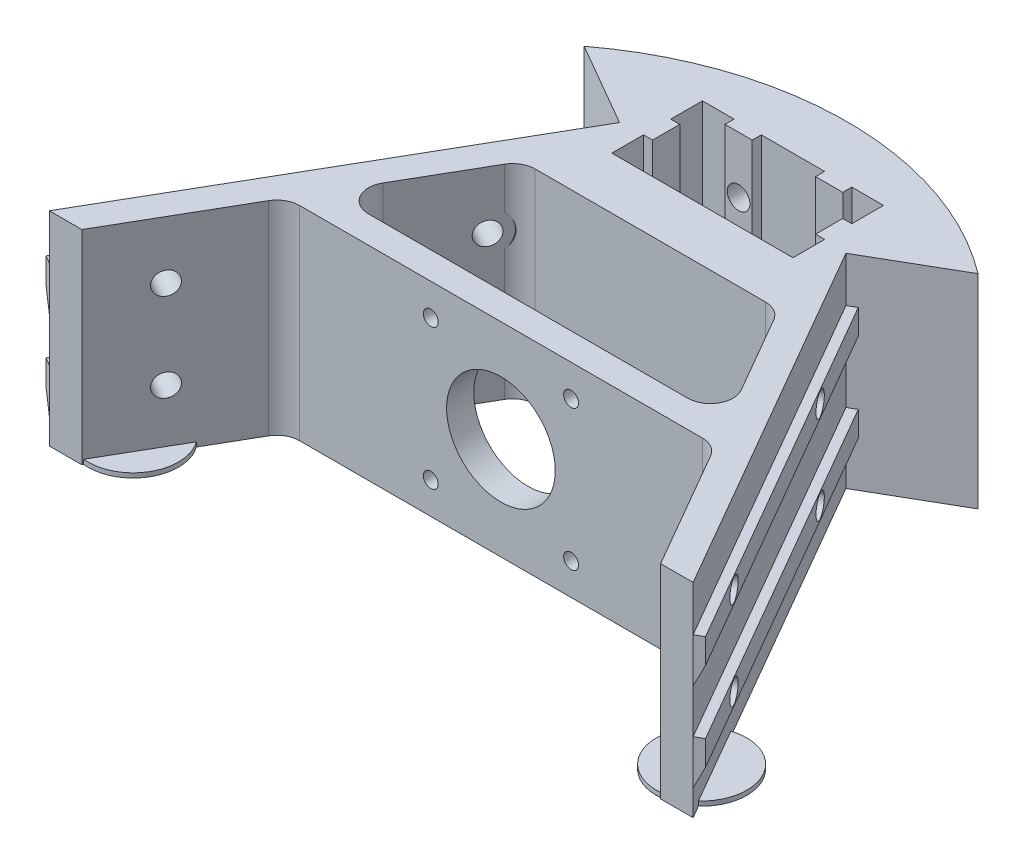
from build123d import *

# Parameters (mm, degrees)
BOSS_EXTRUDE1_DEPTH     = 45
CUT_EXTRUDE1_REACH      = 115.721
SKETCH2_R               = 12
SKETCH2_R_2             = 1.65
SKETCH3_W               = 92.200496998
SKETCH3_H               = 5.5
BOSS_EXTRUDE2_DEPTH     = 2
CUT_EXTRUDE2_REACH      = 137.868
SKETCH4_R               = 2.5
CUT_EXTRUDE6_REACH      = 130.334
SKETCH7_R               = 4.5
CUT_EXTRUDE3_REACH      = 127.051
CUT_EXTRUDE3_END_RADIUS = 72
SKETCH5_R               = 2.5
CUT_EXTRUDE5_START      = -14
SKETCH6_R               = 4.25
CUT_EXTRUDE5_DEPTH      = 1.7
SKETCH8_R               = 10
BOSS_EXTRUDE3_DEPTH     = 1
BOSS_EXTRUDE4_DEPTH     = 0.7
LPATTERN1_COUNT         = 46
LPATTERN1_PITCH         = 2
BOSS_EXTRUDE5_DEPTH     = 0.7
LPATTERN2_COUNT         = 46
LPATTERN2_PITCH         = 2


with BuildPart() as part:
    # Sketch1 → Boss-Extrude1 (new body)
    with BuildSketch(Plane(origin=(0, 0, 0), x_dir=(1, 0, 0), z_dir=(0, 1, 0))):
        with BuildLine():
            Line((67.073634163, -66.174942219), (25, 6.698729811))
            Line((25, 6.698729811), (43.49555567, 17.377143855))
            ThreePointArc((43.49555567, 17.377143855), (0, 32), (-43.49555567, 17.377143855))
            Line((-43.49555567, 17.377143855), (-25, 6.698729811))
            Line((-25, 6.698729811), (-67.073634163, -66.174942219))
            Line((-67.073634163, -66.174942219), (-71.100248499, -73.149242831))
            Line((-71.100248499, -73.149242831), (-63.915003714, -73.149242831))
            Line((-63.915003714, -73.149242831), (-48.817731326, -47))
            ThreePointArc((-48.817731326, -47), (-46.987604307, -45.169872981), (-44.487604307, -44.5))
            Line((-44.487604307, -44.5), (44.487604307, -44.5))
            ThreePointArc((44.487604307, -44.5), (46.987604307, -45.169872981), (48.817731326, -47))
            Line((48.817731326, -47), (63.915003714, -73.149242831))
            Line((63.915003714, -73.149242831), (71.100248499, -73.149242831))
            Line((71.100248499, -73.149242831), (67.073634163, -66.174942219))
        make_face()
        Polygon((-20, 20), (-13, 20), (-13, 18), (-7, 18), (-7, 20), (7, 20), (7, 18), (13, 18), (13, 20), (20, 20), (20, 13), (18, 13), (18, 7), (20, 7), (20, 0), (-20, 0), (-20, 7), (-18, 7), (-18, 13), (-20, 13), align=None, mode=Mode.SUBTRACT)
        with BuildLine():
            Line((-25.435045424, -11.5), (25.435045424, -11.5))
            ThreePointArc((25.435045424, -11.5), (27.935045424, -12.169872981), (29.765172443, -14))
            Line((29.765172443, -14), (39.580127019, -31))
            ThreePointArc((39.580127019, -31), (39.580127019, -36), (35.25, -38.5))
            Line((35.25, -38.5), (-35.25, -38.5))
            ThreePointArc((-35.25, -38.5), (-39.580127019, -36), (-39.580127019, -31))
            Line((-39.580127019, -31), (-29.765172443, -14))
            ThreePointArc((-29.765172443, -14), (-27.935045424, -12.169872981), (-25.435045424, -11.5))
        make_face(mode=Mode.SUBTRACT)
    extrude(amount=BOSS_EXTRUDE1_DEPTH)

    # Sketch2 → Cut-Extrude1 (cut, up to next)
    with BuildSketch(Plane.XY.offset(44.5), mode=Mode.PRIVATE) as cut_extrude1_sk1:
        with Locations((0, 22.5)):
            Circle(SKETCH2_R)
    cut_extrude1_tool1 = extrude(cut_extrude1_sk1.sketch, amount=-CUT_EXTRUDE1_REACH, mode=Mode.PRIVATE) & part.part
    # Sketch2 → Cut-Extrude1 (cut, up to next)
    with BuildSketch(Plane.XY.offset(44.5), mode=Mode.PRIVATE) as cut_extrude1_sk2:
        with Locations((-15.5, 38)):
            Circle(SKETCH2_R_2)
    cut_extrude1_tool2 = extrude(cut_extrude1_sk2.sketch, amount=-CUT_EXTRUDE1_REACH, mode=Mode.PRIVATE) & part.part
    # Sketch2 → Cut-Extrude1 (cut, up to next)
    with BuildSketch(Plane.XY.offset(44.5), mode=Mode.PRIVATE) as cut_extrude1_sk3:
        with Locations((15.5, 38)):
            Circle(SKETCH2_R_2)
    cut_extrude1_tool3 = extrude(cut_extrude1_sk3.sketch, amount=-CUT_EXTRUDE1_REACH, mode=Mode.PRIVATE) & part.part
    # Sketch2 → Cut-Extrude1 (cut, up to next)
    with BuildSketch(Plane.XY.offset(44.5), mode=Mode.PRIVATE) as cut_extrude1_sk4:
        with Locations((15.5, 7)):
            Circle(SKETCH2_R_2)
    cut_extrude1_tool4 = extrude(cut_extrude1_sk4.sketch, amount=-CUT_EXTRUDE1_REACH, mode=Mode.PRIVATE) & part.part
    # Sketch2 → Cut-Extrude1 (cut, up to next)
    with BuildSketch(Plane.XY.offset(44.5), mode=Mode.PRIVATE) as cut_extrude1_sk5:
        with Locations((-15.5, 7)):
            Circle(SKETCH2_R_2)
    cut_extrude1_tool5 = extrude(cut_extrude1_sk5.sketch, amount=-CUT_EXTRUDE1_REACH, mode=Mode.PRIVATE) & part.part
    add(cut_extrude1_tool1.solids().sort_by_distance((0, 22.5, 44.5))[0], mode=Mode.SUBTRACT)
    add(cut_extrude1_tool2.solids().sort_by_distance((-15.5, 38, 44.5))[0], mode=Mode.SUBTRACT)
    add(cut_extrude1_tool3.solids().sort_by_distance((15.5, 38, 44.5))[0], mode=Mode.SUBTRACT)
    add(cut_extrude1_tool4.solids().sort_by_distance((15.5, 7, 44.5))[0], mode=Mode.SUBTRACT)
    add(cut_extrude1_tool5.solids().sort_by_distance((-15.5, 7, 44.5))[0], mode=Mode.SUBTRACT)

    # Sketch3 → Boss-Extrude2 (add)
    with BuildSketch(Plane(origin=(21.650635095, 0, -12.5), x_dir=(-0.49999999999999517, 0, -0.8660254037844414), z_dir=(0.8660254037844414, 0, -0.49999999999999517))):
        with Locations((-52.79897831, 32.25)):
            Rectangle(SKETCH3_W, SKETCH3_H)
        with Locations((-52.79897831, 12.75)):
            Rectangle(SKETCH3_W, SKETCH3_H)
    boss_extrude2 = extrude(amount=BOSS_EXTRUDE2_DEPTH)

    # Sketch4 → Cut-Extrude2 (cut, up to next)
    with BuildSketch(Plane(origin=(23.382685902, 0, -13.5), x_dir=(-0.4999999999999952, 0, -0.8660254037844415), z_dir=(0.8660254037844415, 0, -0.4999999999999953)), mode=Mode.PRIVATE) as cut_extrude2_sk1:
        with Locations((-29.698729811, 32.25)):
            Circle(SKETCH4_R)
    cut_extrude2_tool1 = extrude(cut_extrude2_sk1.sketch, amount=-CUT_EXTRUDE2_REACH, mode=Mode.PRIVATE) & part.part
    # Sketch4 → Cut-Extrude2 (cut, up to next)
    with BuildSketch(Plane(origin=(23.382685902, 0, -13.5), x_dir=(-0.4999999999999952, 0, -0.8660254037844415), z_dir=(0.8660254037844415, 0, -0.4999999999999953)), mode=Mode.PRIVATE) as cut_extrude2_sk2:
        with Locations((-29.698729811, 12.75)):
            Circle(SKETCH4_R)
    cut_extrude2_tool2 = extrude(cut_extrude2_sk2.sketch, amount=-CUT_EXTRUDE2_REACH, mode=Mode.PRIVATE) & part.part
    # Sketch4 → Cut-Extrude2 (cut, up to next)
    with BuildSketch(Plane(origin=(23.382685902, 0, -13.5), x_dir=(-0.4999999999999952, 0, -0.8660254037844415), z_dir=(0.8660254037844415, 0, -0.4999999999999953)), mode=Mode.PRIVATE) as cut_extrude2_sk3:
        with Locations((-81.698729811, 12.75)):
            Circle(SKETCH4_R)
    cut_extrude2_tool3 = extrude(cut_extrude2_sk3.sketch, amount=-CUT_EXTRUDE2_REACH, mode=Mode.PRIVATE) & part.part
    # Sketch4 → Cut-Extrude2 (cut, up to next)
    with BuildSketch(Plane(origin=(23.382685902, 0, -13.5), x_dir=(-0.4999999999999952, 0, -0.8660254037844415), z_dir=(0.8660254037844415, 0, -0.4999999999999953)), mode=Mode.PRIVATE) as cut_extrude2_sk4:
        with Locations((-81.698729811, 32.25)):
            Circle(SKETCH4_R)
    cut_extrude2_tool4 = extrude(cut_extrude2_sk4.sketch, amount=-CUT_EXTRUDE2_REACH, mode=Mode.PRIVATE) & part.part
    cut_extrude2_1 = cut_extrude2_tool1.solids().sort_by_distance((38.232051, 32.25, 12.219854))[0]
    add(cut_extrude2_1, mode=Mode.SUBTRACT)
    cut_extrude2_2 = cut_extrude2_tool2.solids().sort_by_distance((38.232051, 12.75, 12.219854))[0]
    add(cut_extrude2_2, mode=Mode.SUBTRACT)
    cut_extrude2_3 = cut_extrude2_tool3.solids().sort_by_distance((64.232051, 12.75, 57.253175))[0]
    add(cut_extrude2_3, mode=Mode.SUBTRACT)
    cut_extrude2_4 = cut_extrude2_tool4.solids().sort_by_distance((64.232051, 32.25, 57.253175))[0]
    add(cut_extrude2_4, mode=Mode.SUBTRACT)
    cut_extrude2 = cut_extrude2_1 + cut_extrude2_2 + cut_extrude2_3 + cut_extrude2_4  # Cut-Extrude2 as one shape, for the pattern or mirror that repeats it

    # Sketch7 → Cut-Extrude6 (cut, up to next)
    with BuildSketch(Plane(origin=(16.261701506, 0, -9.388697742), x_dir=(0.49999999999999534, 0, 0.8660254037844414), z_dir=(-0.8660254037844415, 0, 0.4999999999999954)), mode=Mode.PRIVATE) as cut_extrude6_sk1:
        with Locations((29.698729811, 32.25)):
            Circle(SKETCH7_R)
    cut_extrude6_tool1 = extrude(cut_extrude6_sk1.sketch, amount=CUT_EXTRUDE6_REACH, mode=Mode.PRIVATE) & part.part
    # Sketch7 → Cut-Extrude6 (cut, up to next)
    with BuildSketch(Plane(origin=(16.261701506, 0, -9.388697742), x_dir=(0.49999999999999534, 0, 0.8660254037844414), z_dir=(-0.8660254037844415, 0, 0.4999999999999954)), mode=Mode.PRIVATE) as cut_extrude6_sk2:
        with Locations((29.698729811, 12.75)):
            Circle(SKETCH7_R)
    cut_extrude6_tool2 = extrude(cut_extrude6_sk2.sketch, amount=CUT_EXTRUDE6_REACH, mode=Mode.PRIVATE) & part.part
    cut_extrude6_1 = cut_extrude6_tool1.solids().sort_by_distance((31.111066, 32.25, 16.331157))[0]
    add(cut_extrude6_1, mode=Mode.SUBTRACT)
    cut_extrude6_2 = cut_extrude6_tool2.solids().sort_by_distance((31.111066, 12.75, 16.331157))[0]
    add(cut_extrude6_2, mode=Mode.SUBTRACT)
    cut_extrude6 = cut_extrude6_1 + cut_extrude6_2  # Cut-Extrude6 as one shape, for the pattern or mirror that repeats it

    # Cut-Extrude3: up to this cylinder (the profile starts inside it)
    cut_extrude3_end = Plane(origin=(0, 22.5, 40), z_dir=(0, -1, 0)) * Cylinder(CUT_EXTRUDE3_END_RADIUS, 419.102, mode=Mode.PRIVATE)
    # Sketch5 → Cut-Extrude3 (cut, up to the surface)
    with BuildSketch(Plane.XY.offset(-18), mode=Mode.PRIVATE) as cut_extrude3_sk1:
        with Locations((10, 32.5)):
            Circle(SKETCH5_R)
    cut_extrude3_tool1 = extrude(cut_extrude3_sk1.sketch, amount=-CUT_EXTRUDE3_REACH, mode=Mode.PRIVATE) & cut_extrude3_end
    # Sketch5 → Cut-Extrude3 (cut, up to the surface)
    with BuildSketch(Plane.XY.offset(-18), mode=Mode.PRIVATE) as cut_extrude3_sk2:
        with Locations((10, 12.5)):
            Circle(SKETCH5_R)
    cut_extrude3_tool2 = extrude(cut_extrude3_sk2.sketch, amount=-CUT_EXTRUDE3_REACH, mode=Mode.PRIVATE) & cut_extrude3_end
    cut_extrude3 = cut_extrude3_tool1.solids().sort_by_distance((10, 32.5, -18))[0] + cut_extrude3_tool2.solids().sort_by_distance((10, 12.5, -18))[0]
    add(cut_extrude3, mode=Mode.SUBTRACT)

    # Sketch6 → Cut-Extrude5 (cut)
    with BuildSketch(Plane.XY.offset(-18).offset(CUT_EXTRUDE5_START)):
        with Locations(Location((10, 32.5, 0), (0, 0, 180))):
            Circle(SKETCH6_R)
        with Locations(Location((10, 12.5, 0), (0, 0, 180))):
            Circle(SKETCH6_R)
    cut_extrude5 = extrude(amount=CUT_EXTRUDE5_DEPTH, mode=Mode.SUBTRACT)

    # Mirror1: Boss-Extrude2, Cut-Extrude2, Cut-Extrude6, Cut-Extrude3, Cut-Extrude5 across plane
    add(boss_extrude2.mirror(Plane(origin=(0, 0, 0), x_dir=(0, 0, 1), z_dir=(1, 0, 0))))
    add(cut_extrude2.mirror(Plane(origin=(0, 0, 0), x_dir=(0, 0, 1), z_dir=(1, 0, 0))), mode=Mode.SUBTRACT)
    add(cut_extrude6.mirror(Plane(origin=(0, 0, 0), x_dir=(0, 0, 1), z_dir=(1, 0, 0))), mode=Mode.SUBTRACT)
    add(cut_extrude3.mirror(Plane(origin=(0, 0, 0), x_dir=(0, 0, 1), z_dir=(1, 0, 0))), mode=Mode.SUBTRACT)
    add(cut_extrude5.mirror(Plane(origin=(0, 0, 0), x_dir=(0, 0, 1), z_dir=(1, 0, 0))), mode=Mode.SUBTRACT)

    # Sketch8 → Boss-Extrude3 (add)
    with BuildSketch(Plane(origin=(0, 0, 0), x_dir=(1, 0, 0), z_dir=(0, 1, 0))):
        with Locations((62.771807108, -62.946563711)):
            Circle(SKETCH8_R)
        with Locations((-62.771807108, -62.946563711)):
            Circle(SKETCH8_R)
    extrude(amount=BOSS_EXTRUDE3_DEPTH)

    # Sketch10 → Boss-Extrude4 (add)
    with BuildSketch(Plane(origin=(49.449613404, 0, 85.649242831), x_dir=(0.8660254037844415, 0, -0.4999999999999951), z_dir=(0.49999999999999517, 0, 0.8660254037844416))):
        Polygon((25, 29.5), (27, 29.5), (25, 25.210986159), align=None)
        Polygon((25, 10), (27, 10), (25, 5.710986159), align=None)
    boss_extrude4 = extrude(amount=-BOSS_EXTRUDE4_DEPTH)

    # LPattern1: Boss-Extrude4 ×46
    with Locations(*[Vector(-0.49999999999999356, 0, -0.8660254037844424) * (i * LPATTERN1_PITCH) for i in range(1, LPATTERN1_COUNT)]):
        add(boss_extrude4)

    # Sketch11 → Boss-Extrude5 (add)
    with BuildSketch(Plane(origin=(-49.449613404, 0, 85.649242831), x_dir=(0.8660254037844414, 0, 0.49999999999999534), z_dir=(-0.4999999999999954, 0, 0.8660254037844415))):
        Polygon((-25, 29.5), (-27, 29.5), (-25, 25.210986159), align=None)
        Polygon((-25, 10), (-27, 10), (-25, 5.710986159), align=None)
    boss_extrude5 = extrude(amount=-BOSS_EXTRUDE5_DEPTH)

    # LPattern2: Boss-Extrude5 ×46
    with Locations(*[Vector(0.49999999999999367, -1.1113072267976953e-15, -0.8660254037844424) * (i * LPATTERN2_PITCH) for i in range(1, LPATTERN2_COUNT)]):
        add(boss_extrude5)


solid = part.part
